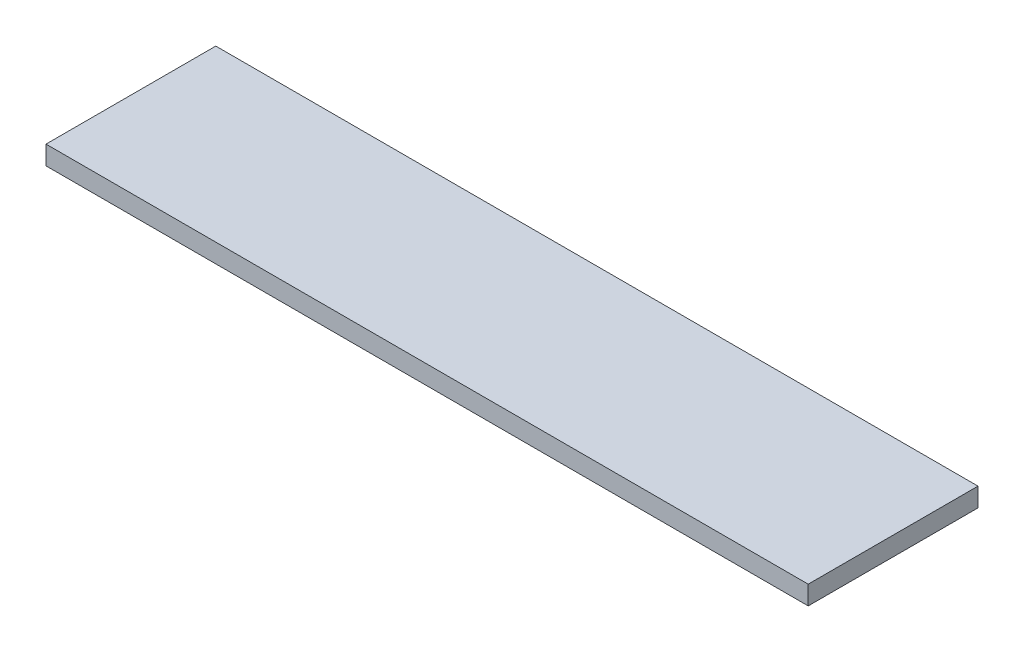
from build123d import *

# Parameters (mm, degrees)
ESQUISSE1_W        = 202
ESQUISSE1_H        = 5
BOSS_EXTRU_1_DEPTH = 45


with BuildPart() as part:
    # Esquisse1 → Boss.-Extru.1 (new body)
    with BuildSketch(Plane.XY):
        with Locations((101, 2.5)):
            Rectangle(ESQUISSE1_W, ESQUISSE1_H)
    extrude(amount=BOSS_EXTRU_1_DEPTH)


solid = part.part
